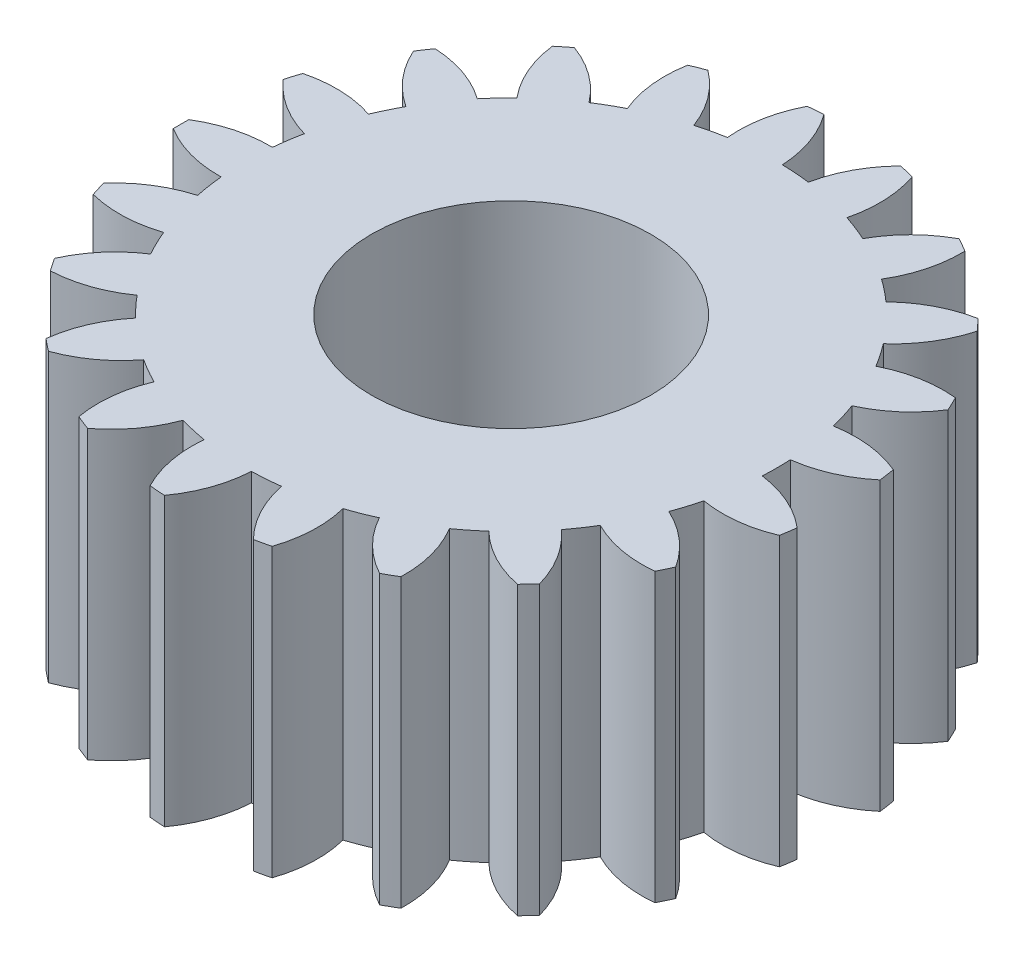
from build123d import *

# Parameters (mm, degrees)
SKETCH1_R           = 27.5
BOSS_EXTRUDE1_DEPTH = 20
SKETCH2_R           = 27.5
CUT_EXTRUDE1_DEPTH  = 15
SKETCH5_R           = 27.5
CUT_EXTRUDE4_DEPTH  = 5
SKETCH3_R           = 9.725
CUT_EXTRUDE2_DEPTH  = 18
SKETCH4_R           = 5.5
CUT_EXTRUDE3_DEPTH  = 2


with BuildPart() as part:
    # Sketch1 → Boss-Extrude1 (new body)
    with BuildSketch(Plane(origin=(0, 0, 0), x_dir=(1, 0, 0), z_dir=(0, 1, 0))):
        Circle(SKETCH1_R)
    extrude(amount=BOSS_EXTRUDE1_DEPTH)

    # Sketch2 → Cut-Extrude1 (cut)
    with BuildSketch(Plane(origin=(-17.553334409, 15, -44.693665049), x_dir=(1, 0, 0), z_dir=(0, 1, 0))):
        with Locations((17.553334409, -44.693665049)):
            Circle(SKETCH2_R)
        with BuildLine():
            ThreePointArc((19.907885811, -63.042209643), (20.721289209, -65.29792668), (22.138882319, -67.231915877))
            ThreePointArc((22.138882319, -67.231915877), (22.67131589, -67.117007029), (23.200879042, -66.989522055))
            ThreePointArc((23.200879042, -66.989522055), (23.638959837, -64.631987399), (23.393092033, -62.246734066))
            ThreePointArc((23.393092033, -62.246734066), (24.311778018, -61.913898525), (25.211608161, -61.533019079))
            ThreePointArc((25.211608161, -61.533019079), (26.653758596, -63.448766077), (28.578425345, -64.878990656))
            ThreePointArc((28.578425345, -64.878990656), (29.053334409, -64.612249336), (29.5217937, -64.334336682))
            ThreePointArc((29.5217937, -64.334336682), (29.245516256, -61.952414095), (28.307505906, -59.745601682))
            ThreePointArc((28.307505906, -59.745601682), (29.087272253, -59.156765643), (29.834859279, -58.527578012))
            ThreePointArc((29.834859279, -58.527578012), (31.777615358, -59.933132443), (34.038340658, -60.732510673))
            ThreePointArc((34.038340658, -60.732510673), (34.413527461, -60.337638018), (34.779258227, -59.933991443))
            ThreePointArc((34.779258227, -59.933991443), (33.813171007, -57.7393252), (32.266364448, -55.907038675))
            ThreePointArc((32.266364448, -55.907038675), (32.837925495, -55.114522803), (33.366843017, -54.292933069))
            ThreePointArc((33.366843017, -54.292933069), (35.637582335, -55.063405253), (38.033490823, -55.160908872))
            ThreePointArc((38.033490823, -55.160908872), (38.27561837, -54.672991049), (38.506123829, -54.179476323))
            ThreePointArc((38.506123829, -54.179476323), (36.936067921, -52.36707215), (34.917905703, -51.072118212))
            ThreePointArc((34.917905703, -51.072118212), (35.230475743, -50.146341021), (35.493727118, -49.205351036))
            ThreePointArc((35.493727118, -49.205351036), (37.890684523, -49.272281139), (40.208889215, -48.659246521))
            ThreePointArc((40.208889215, -48.659246521), (40.296443412, -48.121637171), (40.37124214, -47.582105244))
            ThreePointArc((40.37124214, -47.582105244), (38.336723903, -46.313003205), (36.026528596, -45.670444194))
            ThreePointArc((36.026528596, -45.670444194), (36.052334409, -44.693665049), (36.026528596, -43.716885905))
            ThreePointArc((36.026528596, -43.716885905), (38.336723903, -43.074326893), (40.37124214, -41.805224855))
            ThreePointArc((40.37124214, -41.805224855), (40.296443412, -41.265692927), (40.208889215, -40.728083577))
            ThreePointArc((40.208889215, -40.728083577), (37.890684523, -40.115048959), (35.493727118, -40.181979062))
            ThreePointArc((35.493727118, -40.181979062), (35.230475743, -39.240989078), (34.917905703, -38.315211887))
            ThreePointArc((34.917905703, -38.315211887), (36.936067921, -37.020257949), (38.506123829, -35.207853775))
            ThreePointArc((38.506123829, -35.207853775), (38.27561837, -34.71433905), (38.033490823, -34.226421227))
            ThreePointArc((38.033490823, -34.226421227), (35.637582335, -34.323924846), (33.366843017, -35.09439703))
            ThreePointArc((33.366843017, -35.09439703), (32.837925495, -34.272807295), (32.266364448, -33.480291423))
            ThreePointArc((32.266364448, -33.480291423), (33.813171007, -31.648004899), (34.779258227, -29.453338655))
            ThreePointArc((34.779258227, -29.453338655), (34.413527461, -29.049692081), (34.038340658, -28.654819425))
            ThreePointArc((34.038340658, -28.654819425), (31.777615358, -29.454197656), (29.834859279, -30.859752087))
            ThreePointArc((29.834859279, -30.859752087), (29.087272253, -30.230564455), (28.307505906, -29.641728416))
            ThreePointArc((28.307505906, -29.641728416), (29.245516256, -27.434916004), (29.5217937, -25.052993416))
            ThreePointArc((29.5217937, -25.052993416), (29.053334409, -24.775080762), (28.578425345, -24.508339442))
            ThreePointArc((28.578425345, -24.508339442), (26.653758596, -25.938564021), (25.211608161, -27.854311019))
            ThreePointArc((25.211608161, -27.854311019), (24.311778018, -27.473431573), (23.393092033, -27.140596033))
            ThreePointArc((23.393092033, -27.140596033), (23.638959837, -24.7553427), (23.200879042, -22.397808044))
            ThreePointArc((23.200879042, -22.397808044), (22.67131589, -22.270323069), (22.138882319, -22.155414222))
            ThreePointArc((22.138882319, -22.155414222), (20.721289209, -24.089403419), (19.907885811, -26.345120456))
            ThreePointArc((19.907885811, -26.345120456), (18.93576641, -26.246392005), (17.959790067, -26.199130862))
            ThreePointArc((17.959790067, -26.199130862), (17.491668892, -23.847376835), (16.378155259, -21.72370741))
            ThreePointArc((16.378155259, -21.72370741), (15.834542256, -21.757977714), (15.291893237, -21.805111495))
            ThreePointArc((15.291893237, -21.805111495), (14.507333135, -24.071021882), (14.394951237, -26.466278601))
            ThreePointArc((14.394951237, -26.466278601), (13.436919651, -26.658473602), (12.490372733, -26.900986216))
            ThreePointArc((12.490372733, -26.900986216), (11.3498572, -24.79169516), (9.659851301, -23.090588314))
            ThreePointArc((9.659851301, -23.090588314), (9.150490848, -23.28356883), (8.645843129, -23.488557195))
            ThreePointArc((8.645843129, -23.488557195), (8.564027642, -25.885052692), (9.162652868, -28.207020021))
            ThreePointArc((9.162652868, -28.207020021), (8.303834409, -28.673061105), (7.470821762, -29.183799166))
            ThreePointArc((7.470821762, -29.183799166), (5.759251681, -27.504390848), (3.642917957, -26.37699739))
            ThreePointArc((3.642917957, -26.37699739), (3.213068966, -26.711540953), (2.79126271, -27.056169786))
            ThreePointArc((2.79126271, -27.056169786), (3.419461503, -29.37031125), (4.675903376, -31.412672203))
            ThreePointArc((4.675903376, -31.412672203), (3.992607832, -32.111149573), (3.347146286, -32.844731764))
            ThreePointArc((3.347146286, -32.844731764), (1.21660217, -31.744428983), (-1.13801384, -31.290922769))
            ThreePointArc((-1.13801384, -31.290922769), (-1.450157401, -31.737303714), (-1.751642856, -32.190951232))
            ThreePointArc((-1.751642856, -32.190951232), (-0.469248002, -34.217117039), (1.333370142, -35.798398881))
            ThreePointArc((1.333370142, -35.798398881), (0.886311321, -36.667249759), (0.485752967, -37.558494082))
            ThreePointArc((0.485752967, -37.558494082), (-1.87445699, -37.135063569), (-4.25813732, -37.395740616))
            ThreePointArc((-4.25813732, -37.395740616), (-4.424840124, -37.914296038), (-4.579216474, -38.436653668))
            ThreePointArc((-4.579216474, -38.436653668), (-2.756571969, -39.994810093), (-0.567948086, -40.974508995))
            ThreePointArc((-0.567948086, -40.974508995), (-0.739047046, -41.936532167), (-0.85911084, -42.906247653))
            ThreePointArc((-0.85911084, -42.906247653), (-3.239271626, -43.197313067), (-5.440215819, -44.149011076))
            ThreePointArc((-5.440215819, -44.149011076), (-5.446665591, -44.693665049), (-5.440215819, -45.238319023))
            ThreePointArc((-5.440215819, -45.238319023), (-3.239271626, -46.190017032), (-0.85911084, -46.481082446))
            ThreePointArc((-0.85911084, -46.481082446), (-0.739047046, -47.450797931), (-0.567948086, -48.412821103))
            ThreePointArc((-0.567948086, -48.412821103), (-2.756571969, -49.392520005), (-4.579216474, -50.950676431))
            ThreePointArc((-4.579216474, -50.950676431), (-4.424840124, -51.473034061), (-4.25813732, -51.991589483))
            ThreePointArc((-4.25813732, -51.991589483), (-1.87445699, -52.25226653), (0.485752967, -51.828836017))
            ThreePointArc((0.485752967, -51.828836017), (0.886311321, -52.720080339), (1.333370142, -53.588931217))
            ThreePointArc((1.333370142, -53.588931217), (-0.469248002, -55.17021306), (-1.751642856, -57.196378867))
            ThreePointArc((-1.751642856, -57.196378867), (-1.450157401, -57.650026385), (-1.13801384, -58.09640733))
            ThreePointArc((-1.13801384, -58.09640733), (1.21660217, -57.642901116), (3.347146286, -56.542598335))
            ThreePointArc((3.347146286, -56.542598335), (3.992607832, -57.276180525), (4.675903376, -57.974657896))
            ThreePointArc((4.675903376, -57.974657896), (3.419461503, -60.017018849), (2.79126271, -62.331160312))
            ThreePointArc((2.79126271, -62.331160312), (3.213068966, -62.675789146), (3.642917957, -63.010332709))
            ThreePointArc((3.642917957, -63.010332709), (5.759251681, -61.882939251), (7.470821762, -60.203530933))
            ThreePointArc((7.470821762, -60.203530933), (8.303834409, -60.714268994), (9.162652868, -61.180310077))
            ThreePointArc((9.162652868, -61.180310077), (8.564027642, -63.502277407), (8.645843129, -65.898772903))
            ThreePointArc((8.645843129, -65.898772903), (9.150490848, -66.103761268), (9.659851301, -66.296741785))
            ThreePointArc((9.659851301, -66.296741785), (11.3498572, -64.595634939), (12.490372733, -62.486343883))
            ThreePointArc((12.490372733, -62.486343883), (13.436919651, -62.728856497), (14.394951237, -62.921051498))
            ThreePointArc((14.394951237, -62.921051498), (14.507333135, -65.316308216), (15.291893237, -67.582218604))
            ThreePointArc((15.291893237, -67.582218604), (15.834542256, -67.629352384), (16.378155259, -67.663622689))
            ThreePointArc((16.378155259, -67.663622689), (17.491668892, -65.539953264), (17.959790067, -63.188199236))
            ThreePointArc((17.959790067, -63.188199236), (18.93576641, -63.140938093), (19.907885811, -63.042209643))
        make_face(mode=Mode.SUBTRACT)
    extrude(amount=-CUT_EXTRUDE1_DEPTH, mode=Mode.SUBTRACT)

    # Sketch5 → Cut-Extrude4 (cut)
    with BuildSketch(Plane.XZ.offset(-15)):
        Circle(SKETCH5_R)
        with BuildLine():
            ThreePointArc((2.354551403, 18.348544593), (1.382432001, 18.447273044), (0.406455658, 18.494534187))
            ThreePointArc((0.406455658, 18.494534187), (-0.061665516, 20.846288214), (-1.17517915, 22.96995764))
            ThreePointArc((-1.17517915, 22.96995764), (-1.718792152, 22.935687335), (-2.261441171, 22.888553555))
            ThreePointArc((-2.261441171, 22.888553555), (-3.046001274, 20.622643167), (-3.158383172, 18.227386448))
            ThreePointArc((-3.158383172, 18.227386448), (-4.116414757, 18.035191447), (-5.062961676, 17.792678833))
            ThreePointArc((-5.062961676, 17.792678833), (-6.203477209, 19.901969889), (-7.893483108, 21.603076735))
            ThreePointArc((-7.893483108, 21.603076735), (-8.40284356, 21.410096219), (-8.90749128, 21.205107854))
            ThreePointArc((-8.90749128, 21.205107854), (-8.989306767, 18.808612357), (-8.390681541, 16.486645028))
            ThreePointArc((-8.390681541, 16.486645028), (-9.2495, 16.020603945), (-10.082512647, 15.509865883))
            ThreePointArc((-10.082512647, 15.509865883), (-11.794082728, 17.189274201), (-13.910416451, 18.316667659))
            ThreePointArc((-13.910416451, 18.316667659), (-14.340265443, 17.982124097), (-14.762071699, 17.637495263))
            ThreePointArc((-14.762071699, 17.637495263), (-14.133872905, 15.323353799), (-12.877431033, 13.280992846))
            ThreePointArc((-12.877431033, 13.280992846), (-13.560726577, 12.582515476), (-14.206188123, 11.848933286))
            ThreePointArc((-14.206188123, 11.848933286), (-16.336732239, 12.949236066), (-18.691348249, 13.402742281))
            ThreePointArc((-18.691348249, 13.402742281), (-19.003491809, 12.956361335), (-19.304977265, 12.502713817))
            ThreePointArc((-19.304977265, 12.502713817), (-18.02258241, 10.476548011), (-16.219964266, 8.895266168))
            ThreePointArc((-16.219964266, 8.895266168), (-16.667023087, 8.02641529), (-17.067581442, 7.135170968))
            ThreePointArc((-17.067581442, 7.135170968), (-19.427791398, 7.55860148), (-21.811471729, 7.297924433))
            ThreePointArc((-21.811471729, 7.297924433), (-21.978174533, 6.779369011), (-22.132550883, 6.257011382))
            ThreePointArc((-22.132550883, 6.257011382), (-20.309906377, 4.698854956), (-18.121282495, 3.719156054))
            ThreePointArc((-18.121282495, 3.719156054), (-18.292381454, 2.757132882), (-18.412445249, 1.787417397))
            ThreePointArc((-18.412445249, 1.787417397), (-20.792606034, 1.496351982), (-22.993550227, 0.544653974))
            ThreePointArc((-22.993550227, 0.544653974), (-23, 0), (-22.993550227, -0.544653974))
            ThreePointArc((-22.993550227, -0.544653974), (-20.792606034, -1.496351982), (-18.412445249, -1.787417397))
            ThreePointArc((-18.412445249, -1.787417397), (-18.292381454, -2.757132882), (-18.121282495, -3.719156054))
            ThreePointArc((-18.121282495, -3.719156054), (-20.309906377, -4.698854956), (-22.132550883, -6.257011382))
            ThreePointArc((-22.132550883, -6.257011382), (-21.978174533, -6.779369011), (-21.811471729, -7.297924433))
            ThreePointArc((-21.811471729, -7.297924433), (-19.427791398, -7.55860148), (-17.067581442, -7.135170968))
            ThreePointArc((-17.067581442, -7.135170968), (-16.667023087, -8.02641529), (-16.219964266, -8.895266168))
            ThreePointArc((-16.219964266, -8.895266168), (-18.02258241, -10.476548011), (-19.304977265, -12.502713817))
            ThreePointArc((-19.304977265, -12.502713817), (-19.003491809, -12.956361335), (-18.691348249, -13.402742281))
            ThreePointArc((-18.691348249, -13.402742281), (-16.336732239, -12.949236066), (-14.206188123, -11.848933286))
            ThreePointArc((-14.206188123, -11.848933286), (-13.560726577, -12.582515476), (-12.877431033, -13.280992846))
            ThreePointArc((-12.877431033, -13.280992846), (-14.133872905, -15.323353799), (-14.762071699, -17.637495263))
            ThreePointArc((-14.762071699, -17.637495263), (-14.340265443, -17.982124097), (-13.910416451, -18.316667659))
            ThreePointArc((-13.910416451, -18.316667659), (-11.794082728, -17.189274201), (-10.082512647, -15.509865883))
            ThreePointArc((-10.082512647, -15.509865883), (-9.2495, -16.020603945), (-8.390681541, -16.486645028))
            ThreePointArc((-8.390681541, -16.486645028), (-8.989306767, -18.808612357), (-8.90749128, -21.205107854))
            ThreePointArc((-8.90749128, -21.205107854), (-8.40284356, -21.410096219), (-7.893483108, -21.603076735))
            ThreePointArc((-7.893483108, -21.603076735), (-6.203477209, -19.901969889), (-5.062961676, -17.792678833))
            ThreePointArc((-5.062961676, -17.792678833), (-4.116414757, -18.035191447), (-3.158383172, -18.227386448))
            ThreePointArc((-3.158383172, -18.227386448), (-3.046001274, -20.622643167), (-2.261441171, -22.888553555))
            ThreePointArc((-2.261441171, -22.888553555), (-1.718792152, -22.935687335), (-1.17517915, -22.96995764))
            ThreePointArc((-1.17517915, -22.96995764), (-0.061665516, -20.846288214), (0.406455658, -18.494534187))
            ThreePointArc((0.406455658, -18.494534187), (1.382432001, -18.447273044), (2.354551403, -18.348544593))
            ThreePointArc((2.354551403, -18.348544593), (3.1679548, -20.604261631), (4.58554791, -22.538250828))
            ThreePointArc((4.58554791, -22.538250828), (5.117981481, -22.42334198), (5.647544633, -22.295857006))
            ThreePointArc((5.647544633, -22.295857006), (6.085625428, -19.938322349), (5.839757624, -17.553069016))
            ThreePointArc((5.839757624, -17.553069016), (6.75844361, -17.220233476), (7.658273752, -16.83935403))
            ThreePointArc((7.658273752, -16.83935403), (9.100424187, -18.755101028), (11.025090936, -20.185325607))
            ThreePointArc((11.025090936, -20.185325607), (11.5, -19.918584287), (11.968459291, -19.640671633))
            ThreePointArc((11.968459291, -19.640671633), (11.692181847, -17.258749045), (10.754171497, -15.051936633))
            ThreePointArc((10.754171497, -15.051936633), (11.533937845, -14.463100594), (12.281524871, -13.833912962))
            ThreePointArc((12.281524871, -13.833912962), (14.224280949, -15.239467393), (16.48500625, -16.038845624))
            ThreePointArc((16.48500625, -16.038845624), (16.860193052, -15.643972969), (17.225923819, -15.240326394))
            ThreePointArc((17.225923819, -15.240326394), (16.259836598, -13.04566015), (14.713030039, -11.213373626))
            ThreePointArc((14.713030039, -11.213373626), (15.284591086, -10.420857754), (15.813508608, -9.599268019))
            ThreePointArc((15.813508608, -9.599268019), (18.084247926, -10.369740204), (20.480156415, -10.467243822))
            ThreePointArc((20.480156415, -10.467243822), (20.722283962, -9.979326), (20.95278942, -9.485811274))
            ThreePointArc((20.95278942, -9.485811274), (19.382733513, -7.673407101), (17.364571295, -6.378453163))
            ThreePointArc((17.364571295, -6.378453163), (17.677141334, -5.452675971), (17.940392709, -4.511685987))
            ThreePointArc((17.940392709, -4.511685987), (20.337350114, -4.57861609), (22.655554806, -3.965581472))
            ThreePointArc((22.655554806, -3.965581472), (22.743109003, -3.427972122), (22.817907732, -2.888440194))
            ThreePointArc((22.817907732, -2.888440194), (20.783389495, -1.619338156), (18.473194188, -0.976779145))
            ThreePointArc((18.473194188, -0.976779145), (18.499, 0), (18.473194188, 0.976779145))
            ThreePointArc((18.473194188, 0.976779145), (20.783389495, 1.619338156), (22.817907732, 2.888440194))
            ThreePointArc((22.817907732, 2.888440194), (22.743109003, 3.427972122), (22.655554806, 3.965581472))
            ThreePointArc((22.655554806, 3.965581472), (20.337350114, 4.57861609), (17.940392709, 4.511685987))
            ThreePointArc((17.940392709, 4.511685987), (17.677141334, 5.452675971), (17.364571295, 6.378453163))
            ThreePointArc((17.364571295, 6.378453163), (19.382733513, 7.673407101), (20.95278942, 9.485811274))
            ThreePointArc((20.95278942, 9.485811274), (20.722283962, 9.979326), (20.480156415, 10.467243822))
            ThreePointArc((20.480156415, 10.467243822), (18.084247926, 10.369740204), (15.813508608, 9.599268019))
            ThreePointArc((15.813508608, 9.599268019), (15.284591086, 10.420857754), (14.713030039, 11.213373626))
            ThreePointArc((14.713030039, 11.213373626), (16.259836598, 13.04566015), (17.225923819, 15.240326394))
            ThreePointArc((17.225923819, 15.240326394), (16.860193052, 15.643972969), (16.48500625, 16.038845624))
            ThreePointArc((16.48500625, 16.038845624), (14.224280949, 15.239467393), (12.281524871, 13.833912962))
            ThreePointArc((12.281524871, 13.833912962), (11.533937845, 14.463100594), (10.754171497, 15.051936633))
            ThreePointArc((10.754171497, 15.051936633), (11.692181847, 17.258749045), (11.968459291, 19.640671633))
            ThreePointArc((11.968459291, 19.640671633), (11.5, 19.918584287), (11.025090936, 20.185325607))
            ThreePointArc((11.025090936, 20.185325607), (9.100424187, 18.755101028), (7.658273752, 16.83935403))
            ThreePointArc((7.658273752, 16.83935403), (6.75844361, 17.220233476), (5.839757624, 17.553069016))
            ThreePointArc((5.839757624, 17.553069016), (6.085625428, 19.938322349), (5.647544633, 22.295857006))
            ThreePointArc((5.647544633, 22.295857006), (5.117981481, 22.42334198), (4.58554791, 22.538250828))
            ThreePointArc((4.58554791, 22.538250828), (3.1679548, 20.604261631), (2.354551403, 18.348544593))
        make_face(mode=Mode.SUBTRACT)
    extrude(amount=-CUT_EXTRUDE4_DEPTH, mode=Mode.SUBTRACT)

    # Sketch3 → Cut-Extrude2 (cut)
    with BuildSketch(Plane(origin=(0, 20, 0), x_dir=(1, 0, 0), z_dir=(0, 1, 0))):
        Circle(SKETCH3_R)
    extrude(amount=-CUT_EXTRUDE2_DEPTH, mode=Mode.SUBTRACT)

    # Sketch4 → Cut-Extrude3 (cut)
    with BuildSketch(Plane(origin=(0, 2, 0), x_dir=(1, 0, 0), z_dir=(0, 1, 0))):
        Circle(SKETCH4_R)
    extrude(amount=-CUT_EXTRUDE3_DEPTH, mode=Mode.SUBTRACT)


solid = part.part
